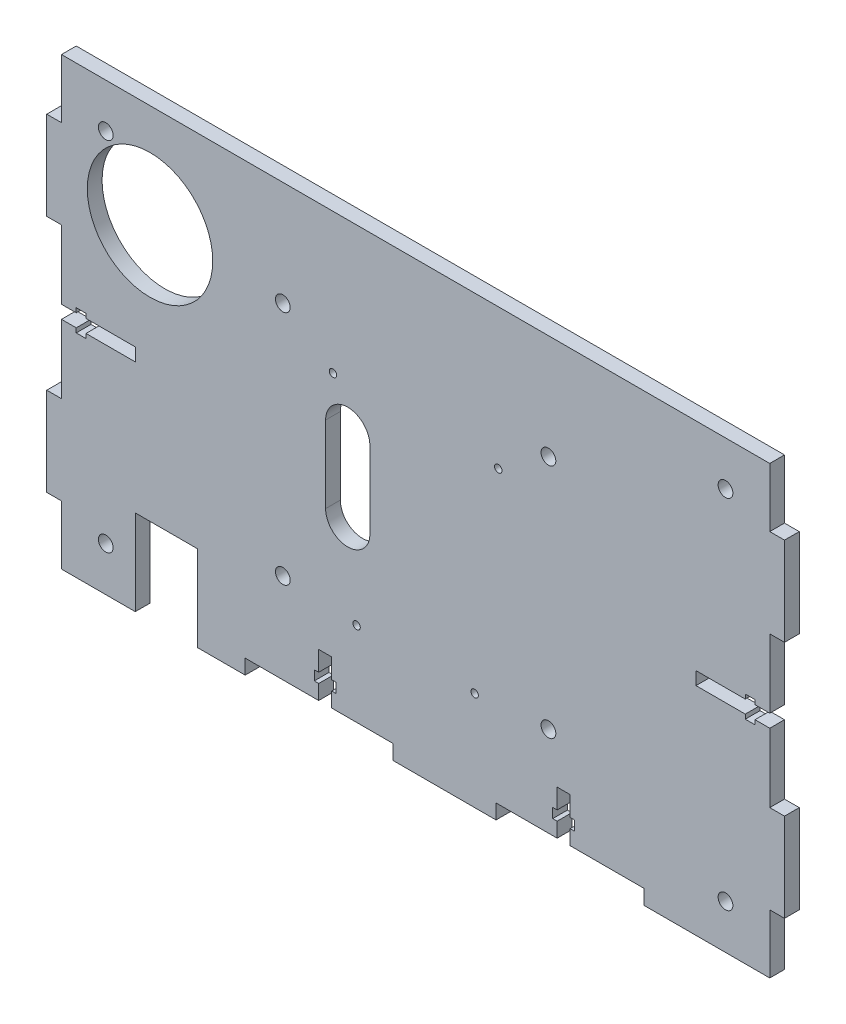
from build123d import *

# Parameters (mm, degrees)
SKETCH1_W           = 240
SKETCH1_H           = 151
BOSS_EXTRUDE1_DEPTH = 5
SKETCH2_R           = 1.25
CUT_EXTRUDE1_DEPTH  = 5
CUT_EXTRUDE2_DEPTH  = 10
SKETCH6_R           = 2.5
CUT_EXTRUDE3_DEPTH  = 10
SKETCH7_R           = 2.5
CUT_EXTRUDE4_DEPTH  = 10
SKETCH8_W           = 21.1
SKETCH8_H           = 29
CUT_EXTRUDE5_DEPTH  = 10
SKETCH9_W           = 5
SKETCH9_H           = 30
BOSS_EXTRUDE2_DEPTH = 5
CUT_EXTRUDE6_DEPTH  = 5
SKETCH11_W          = 50
SKETCH11_H          = 5
SKETCH11_W_2        = 50.1
CUT_EXTRUDE7_DEPTH  = 10
CUT_EXTRUDE8_DEPTH  = 10
SKETCH15_R          = 21.25
CUT_EXTRUDE9_DEPTH  = 10


with BuildPart() as part:
    # Sketch1 → Boss-Extrude1 (new body)
    with BuildSketch(Plane.XY):
        Rectangle(SKETCH1_W, SKETCH1_H)
    extrude(amount=BOSS_EXTRUDE1_DEPTH)

    # Sketch2 → Cut-Extrude1 (cut)
    with BuildSketch(Plane(origin=(0, 0, 0), x_dir=(-1, 0, 0), z_dir=(0, 0, -1))):
        with Locations((28, 28)):
            Circle(SKETCH2_R)
        with Locations((-28, 28)):
            Circle(SKETCH2_R)
        with Locations((20, -42)):
            Circle(SKETCH2_R)
        with Locations((-20, -42)):
            Circle(SKETCH2_R)
    extrude(amount=-CUT_EXTRUDE1_DEPTH, mode=Mode.SUBTRACT)

    # Sketch5 → Cut-Extrude2 (cut)
    with BuildSketch(Plane(origin=(0, 0, 0), x_dir=(-1, 0, 0), z_dir=(0, 0, -1))):
        with BuildLine():
            Line((15.5, -13), (15.5, 13))
            ThreePointArc((15.5, 13), (23, 20.5), (30.5, 13))
            Line((30.5, 13), (30.5, -13))
            ThreePointArc((30.5, -13), (23, -20.5), (15.5, -13))
        make_face()
    extrude(amount=-CUT_EXTRUDE2_DEPTH, mode=Mode.SUBTRACT)

    # Sketch6 → Cut-Extrude3 (cut)
    with BuildSketch(Plane(origin=(0, 0, 0), x_dir=(-1, 0, 0), z_dir=(0, 0, -1))):
        with Locations((-105, 60.5)):
            Circle(SKETCH6_R)
        with Locations((-105, -60.5)):
            Circle(SKETCH6_R)
        with Locations((105, -60.5)):
            Circle(SKETCH6_R)
        with Locations((105, 60.5)):
            Circle(SKETCH6_R)
    extrude(amount=-CUT_EXTRUDE3_DEPTH, mode=Mode.SUBTRACT)

    # Sketch7 → Cut-Extrude4 (cut)
    with BuildSketch(Plane(origin=(0, 0, 0), x_dir=(-1, 0, 0), z_dir=(0, 0, -1))):
        with Locations((45, 40)):
            Circle(SKETCH7_R)
        with Locations((45, -40)):
            Circle(SKETCH7_R)
        with Locations((-45, 40)):
            Circle(SKETCH7_R)
        with Locations((-45, -40)):
            Circle(SKETCH7_R)
    extrude(amount=-CUT_EXTRUDE4_DEPTH, mode=Mode.SUBTRACT)

    # Sketch8 → Cut-Extrude5 (cut)
    with BuildSketch(Plane(origin=(0, 0, 0), x_dir=(-1, 0, 0), z_dir=(0, 0, -1))):
        with Locations((84.45, -61)):
            Rectangle(SKETCH8_W, SKETCH8_H)
    extrude(amount=-CUT_EXTRUDE5_DEPTH, mode=Mode.SUBTRACT)

    # Sketch9 → Boss-Extrude2 (add)
    with BuildSketch(Plane(origin=(0, 0, 0), x_dir=(-1, 0, 0), z_dir=(0, 0, -1))):
        with Locations((122.5, 40.5)):
            Rectangle(SKETCH9_W, SKETCH9_H)
        with Locations((122.5, -40.5)):
            Rectangle(SKETCH9_W, SKETCH9_H)
        with Locations((-122.5, -40.5)):
            Rectangle(SKETCH9_W, SKETCH9_H)
        with Locations((-122.5, 40.5)):
            Rectangle(SKETCH9_W, SKETCH9_H)
    extrude(amount=-BOSS_EXTRUDE2_DEPTH)

    # Sketch10 → Cut-Extrude6 (cut)
    with BuildSketch(Plane(origin=(0, 0, 0), x_dir=(-1, 0, 0), z_dir=(0, 0, -1))):
        Polygon((-120, 2.2), (-115, 2.2), (-115, 3.7), (-111.7, 3.7), (-111.7, 2.2), (-95, 2.2), (-95, -2.2), (-111.7, -2.2), (-111.7, -3.7), (-115, -3.7), (-115, -2.2), (-120, -2.2), align=None)
        Polygon((115, -2.2), (120, -2.2), (120, 2.2), (115, 2.2), (115, 3.7), (111.7, 3.7), (111.7, 2.2), (95, 2.2), (95, -2.2), (111.7, -2.2), (111.7, -3.7), (115, -3.7), align=None)
    extrude(amount=-CUT_EXTRUDE6_DEPTH, mode=Mode.SUBTRACT)

    # Sketch11 → Cut-Extrude7 (cut)
    with BuildSketch(Plane(origin=(0, 0, 0), x_dir=(-1, 0, 0), z_dir=(0, 0, -1))):
        with Locations((32.75, -73)):
            Rectangle(SKETCH11_W, SKETCH11_H)
        with Locations((-52.3, -73)):
            Rectangle(SKETCH11_W_2, SKETCH11_H)
    extrude(amount=-CUT_EXTRUDE7_DEPTH, mode=Mode.SUBTRACT)

    # Sketch12 → Cut-Extrude8 (cut)
    with BuildSketch(Plane(origin=(0, 0, 0), x_dir=(-1, 0, 0), z_dir=(0, 0, -1))):
        Polygon((-52.35, -55.5), (-52.35, -62.2), (-53.85, -62.2), (-53.85, -65.5), (-52.35, -65.5), (-52.35, -70.5), (-47.95, -70.5), (-47.95, -65.5), (-46.45, -65.5), (-46.45, -62.2), (-47.95, -62.2), (-47.95, -55.5), align=None)
        Polygon((32.85, -70.5), (28.45, -70.5), (28.45, -65.5), (26.95, -65.5), (26.95, -62.2), (28.45, -62.2), (28.45, -55.5), (32.85, -55.5), (32.85, -62.2), (34.35, -62.2), (34.35, -65.5), (32.85, -65.5), align=None)
    extrude(amount=-CUT_EXTRUDE8_DEPTH, mode=Mode.SUBTRACT)

    # Sketch15 → Cut-Extrude9 (cut)
    with BuildSketch(Plane(origin=(0, 0, 0), x_dir=(-1, 0, 0), z_dir=(0, 0, -1))):
        with Locations((90, 40.5)):
            Circle(SKETCH15_R)
    extrude(amount=-CUT_EXTRUDE9_DEPTH, mode=Mode.SUBTRACT)


solid = part.part
